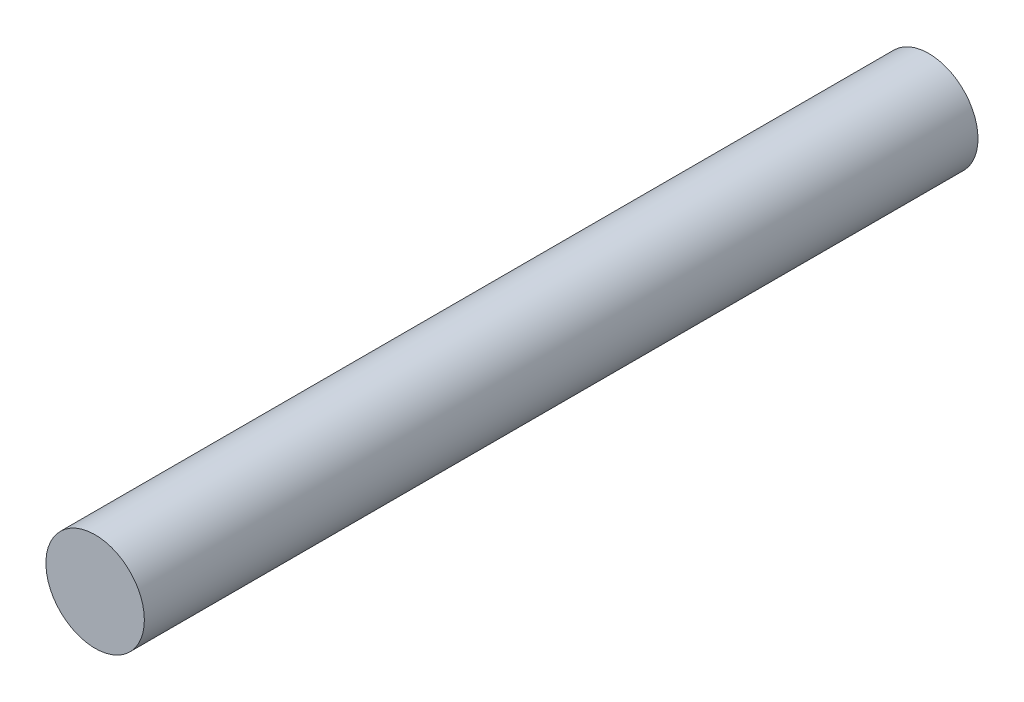
from build123d import *

# Parameters (mm, degrees)
SKETCH3_R           = 1.95
BOSS_EXTRUDE1_DEPTH = 33.02


with BuildPart() as part:
    # Sketch3 → Boss-Extrude1 (new body)
    with BuildSketch(Plane.XY):
        with Locations((-18.152779015, -99.41404144)):
            Circle(SKETCH3_R)
    extrude(amount=-BOSS_EXTRUDE1_DEPTH)


solid = part.part
